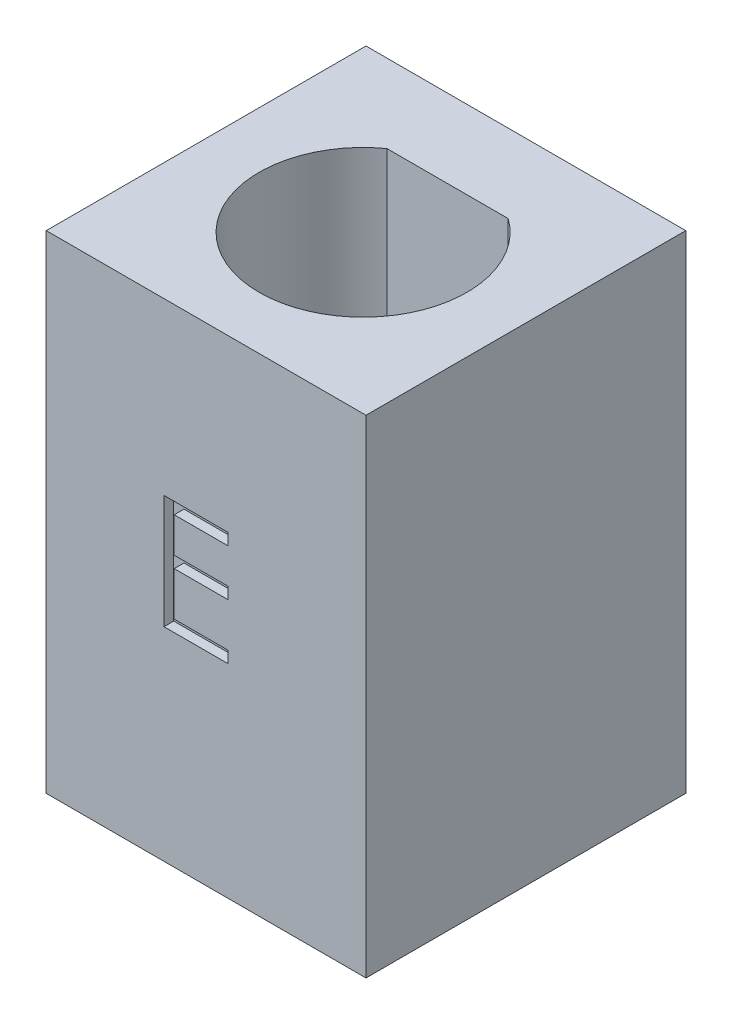
from build123d import *

# Parameters (mm, degrees)
SKETCH1_W           = 9.84142284
SKETCH1_H           = 9.84142284
BOSS_EXTRUDE1_DEPTH = 15
CUT_EXTRUDE1_DEPTH  = 0.3


with BuildPart() as part:
    # Sketch1 → Boss-Extrude1 (new body)
    with BuildSketch(Plane(origin=(0, 0, 0), x_dir=(1, 0, 0), z_dir=(0, 1, 0))):
        Rectangle(SKETCH1_W, SKETCH1_H)
        with BuildLine():
            Line((-1.865475811, 2.509444822), (1.865475811, 2.509444822))
            ThreePointArc((1.865475811, 2.509444822), (0, -3.290555178), (-1.865475811, 2.509444822))
        make_face(mode=Mode.SUBTRACT)
    extrude(amount=BOSS_EXTRUDE1_DEPTH)

    # Sketch2 → Cut-Extrude1 (cut)
    with BuildSketch(Plane.XY.offset(4.92071142)):
        Polygon((-1.296362428, 9.754838654), (0.677996546, 9.754838654), (0.677996546, 9.395864295), (-0.982259864, 9.395864295), (-0.982259864, 8.318941219), (0.677996546, 8.318941219), (0.677996546, 7.95996686), (-0.982259864, 7.95996686), (-0.982259864, 6.613813013), (0.677996546, 6.613813013), (0.677996546, 6.254838654), (-1.296362428, 6.254838654), align=None)
    extrude(amount=-CUT_EXTRUDE1_DEPTH, mode=Mode.SUBTRACT)


solid = part.part
